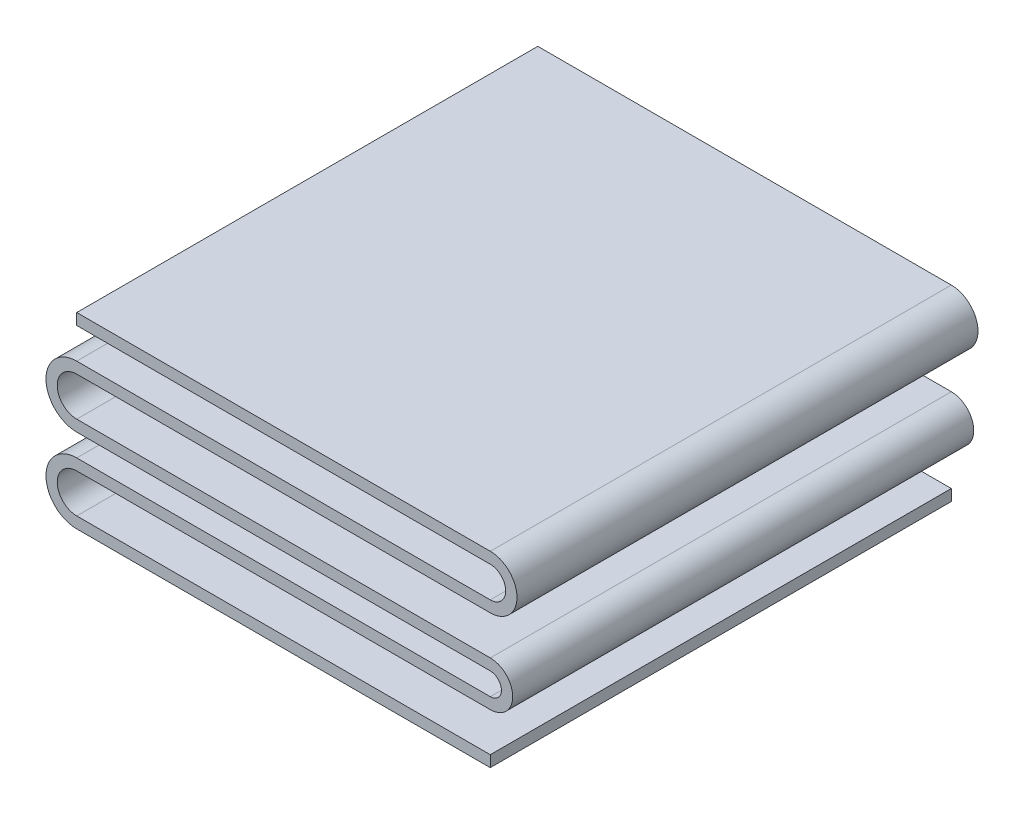
from build123d import *

# Parameters (mm, degrees)
BOSS_EXTRUDE1_DEPTH = 15.621


with BuildPart() as part:
    # Sketch1 → Boss-Extrude1 (new body)
    with BuildSketch(Plane.XY):
        with BuildLine():
            Line((-7.005505105, 0), (7.005505105, 0))
            ThreePointArc((7.005505105, 0), (7.764711356, -0.759206251), (7.005505105, -1.518412501))
            Line((7.005505105, -1.518412501), (-7.005505105, -1.518412501))
            ThreePointArc((-7.005505105, -1.518412501), (-7.666300268, -2.179207663), (-7.005505105, -2.840002826))
            Line((-7.005505105, -2.840002826), (7.005505105, -2.840002826))
            Line((7.005505105, -2.840002826), (7.005505105, -3.221002826))
            Line((7.005505105, -3.221002826), (-7.005505105, -3.221002826))
            ThreePointArc((-7.005505105, -3.221002826), (-8.047300268, -2.179207663), (-7.005505105, -1.137412501))
            Line((-7.005505105, -1.137412501), (7.005505105, -1.137412501))
            ThreePointArc((7.005505105, -1.137412501), (7.383711356, -0.759206251), (7.005505105, -0.381))
            Line((7.005505105, -0.381), (-7.005505105, -0.381))
            ThreePointArc((-7.005505105, -0.381), (-8.047300268, 0.660795162), (-7.005505105, 1.702590324))
            Line((-7.005505105, 1.702590324), (7.005505105, 1.702590324))
            ThreePointArc((7.005505105, 1.702590324), (7.528208531, 2.225293749), (7.005505105, 2.747997174))
            Line((7.005505105, 2.747997174), (-7.005505105, 2.747997174))
            Line((-7.005505105, 2.747997174), (-7.005505105, 3.128997174))
            Line((-7.005505105, 3.128997174), (7.005505105, 3.128997174))
            ThreePointArc((7.005505105, 3.128997174), (7.909208531, 2.225293749), (7.005505105, 1.321590324))
            Line((7.005505105, 1.321590324), (-7.005505105, 1.321590324))
            ThreePointArc((-7.005505105, 1.321590324), (-7.666300268, 0.660795162), (-7.005505105, 0))
        make_face()
    extrude(amount=BOSS_EXTRUDE1_DEPTH)


solid = part.part
